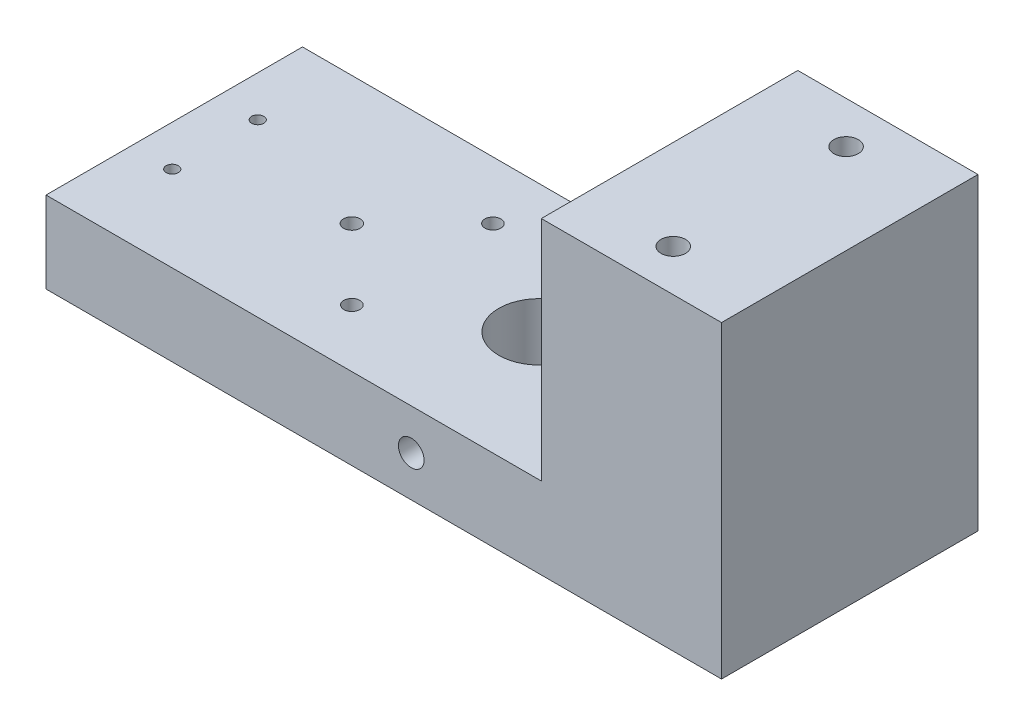
from build123d import *

# Parameters (mm, degrees)
SKETCH2_W                = 40
SKETCH2_H                = 12.7
BOSS_EXTRUDE1_DEPTH      = 105.35
SKETCH4_R                = 6.35
CUT_EXTRUDE1_DEPTH       = 13.7
F_4_0_4_DIAMETER_HOLE1_D = 4
SKETCH9_R                = 1.291519898
SKETCH9_R_2              = 1.25
CUT_EXTRUDE3_DEPTH       = 13.7000001
SKETCH14_W               = 28.1
SKETCH14_H               = 40
BOSS_EXTRUDE3_DEPTH      = 35.45
SKETCH10_R               = 3.75
CUT_EXTRUDE4_DEPTH       = 24.5
SKETCH15_R               = 1.905
CUT_EXTRUDE7_DEPTH       = 24.65
SKETCH17_R               = 0.95
CUT_EXTRUDE8_DEPTH       = 21


with BuildPart() as part:
    # Sketch2 → Boss-Extrude1 (new body)
    with BuildSketch(Plane(origin=(0, 0, 0), x_dir=(0, 0, -1), z_dir=(1, 0, 0))):
        with Locations((-8.031139822, -4.466363736)):
            Rectangle(SKETCH2_W, SKETCH2_H)
    extrude(amount=BOSS_EXTRUDE1_DEPTH)

    # Sketch4 → Cut-Extrude1 (cut, through all)
    with BuildSketch(Plane(origin=(0, 1.883636264, 0), x_dir=(1, 0, 0), z_dir=(0, 1, 0))):
        with Locations((56.96, -8.031139822)):
            Circle(SKETCH4_R)
    extrude(amount=-CUT_EXTRUDE1_DEPTH, mode=Mode.SUBTRACT)

    # Ø4.0 (4) Diameter Hole1 (through all)
    with Locations(Plane.XY.offset(28.031139822)):
        with Locations((56.96, -4.466363736)):
            Hole(F_4_0_4_DIAMETER_HOLE1_D / 2)

    # Sketch9 → Cut-Extrude3 (cut, through all)
    with BuildSketch(Plane(origin=(0, 1.883636264, 0), x_dir=(1, 0, 0), z_dir=(0, 1, 0))):
        with Locations((27.7, -8.031139822)):
            Circle(SKETCH9_R)
        with Locations((38.7, 2.968860178)):
            Circle(SKETCH9_R_2)
        with Locations((38.7, -19.031139822)):
            Circle(SKETCH9_R_2)
    extrude(amount=-CUT_EXTRUDE3_DEPTH, mode=Mode.SUBTRACT)

    # Sketch14 → Boss-Extrude3 (add)
    with BuildSketch(Plane(origin=(0, 1.883636264, 0), x_dir=(1, 0, 0), z_dir=(0, 1, 0))):
        with Locations((91.3, -8.031139822)):
            Rectangle(SKETCH14_W, SKETCH14_H)
    extrude(amount=BOSS_EXTRUDE3_DEPTH)

    # Sketch10 → Cut-Extrude4 (cut)
    with BuildSketch(Plane(origin=(0, -10.816363736, 0), x_dir=(1, 0, 0), z_dir=(0, 1, 0))):
        with Locations((91.3, -21.505839822)):
            Circle(SKETCH10_R)
        with Locations((91.3, 5.443560178)):
            Circle(SKETCH10_R)
    extrude(amount=CUT_EXTRUDE4_DEPTH, mode=Mode.SUBTRACT)

    # Sketch15 → Cut-Extrude7 (cut, through all)
    with BuildSketch(Plane.XZ.offset(-13.683636264)):
        with Locations((91.3, -5.443560178)):
            Circle(SKETCH15_R)
        with Locations((91.3, 21.505839822)):
            Circle(SKETCH15_R)
    extrude(amount=-CUT_EXTRUDE7_DEPTH, mode=Mode.SUBTRACT)

    # Sketch17 → Cut-Extrude8 (cut)
    with BuildSketch(Plane.XZ.offset(10.816363736)):
        with Locations((6.35, 14.698139822)):
            Circle(SKETCH17_R)
        with Locations((6.35, 1.364139822)):
            Circle(SKETCH17_R)
    extrude(amount=-CUT_EXTRUDE8_DEPTH, mode=Mode.SUBTRACT)


solid = part.part
